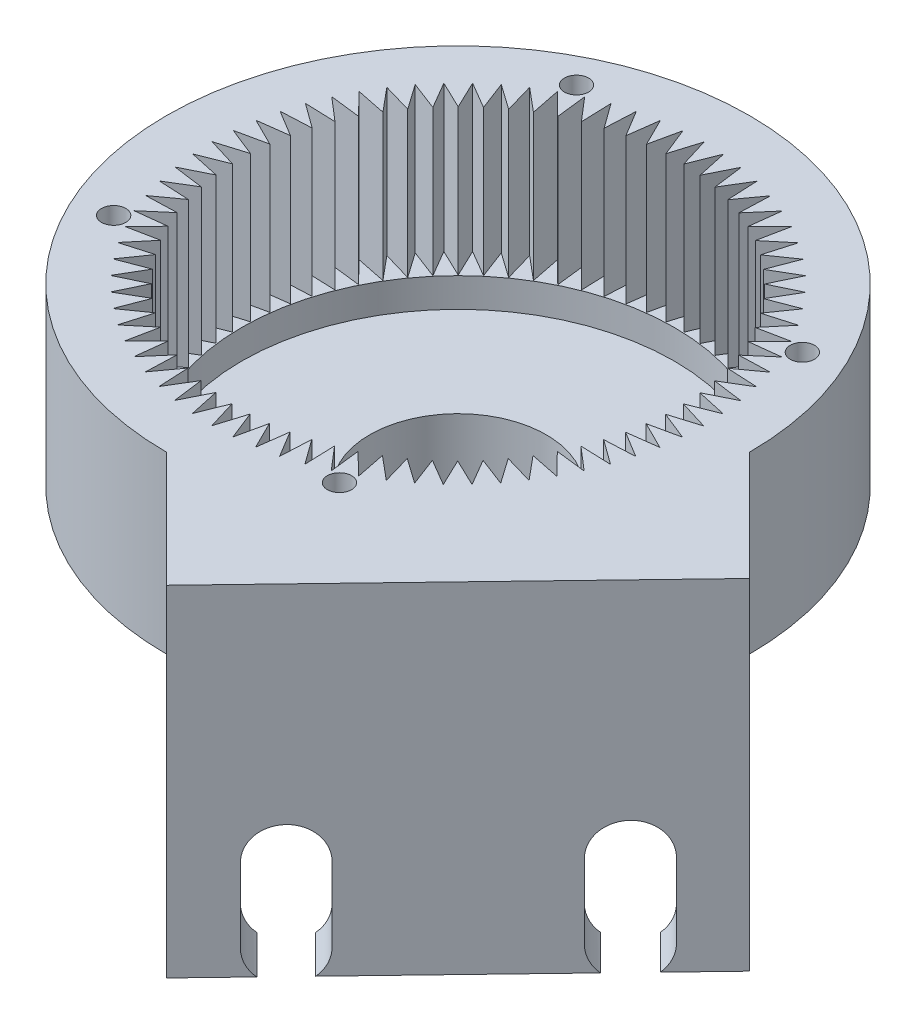
from build123d import *

# Parameters (mm, degrees)
SKETCH1_R                = 23
BOSS_EXTRUDE1_DEPTH      = 2
SKETCH2_R                = 30
SKETCH2_R_2              = 22.25
BOSS_EXTRUDE2_DEPTH      = 18
SKETCH3_R                = 9.1
CUT_EXTRUDE1_DEPTH       = 10
CUT_EXTRUDE8_DEPTH       = 15
SKETCH5_R                = 1.25
CUT_EXTRUDE3_DEPTH       = 47.904157598
SKETCH8_R                = 2.5
CUT_EXTRUDE5_DEPTH       = 2
BOSS_EXTRUDE3_DEPTH      = 20
BOSS_EXTRUDE4_DEPTH      = 17
CUT_EXTRUDE14_DEPTH      = 17
SKETCH19_R               = 10.9
SKETCH19_R_2             = 9.1
BOSS_EXTRUDE5_DEPTH      = 16
CUT_EXTRUDE15_DEPTH      = 62.480682567
CUT_EXTRUDE15_DEPTH_BACK = 62.480682567
SKETCH20_R               = 0.75


with BuildPart() as part:
    # Sketch1 → Boss-Extrude1 (new body)
    with BuildSketch(Plane(origin=(0, 0, 0), x_dir=(1, 0, 0), z_dir=(0, 1, 0))):
        Circle(SKETCH1_R)
    extrude(amount=-BOSS_EXTRUDE1_DEPTH)

    # Sketch2 → Boss-Extrude2 (add)
    with BuildSketch(Plane(origin=(0, 0, 0), x_dir=(1, 0, 0), z_dir=(0, 1, 0))):
        Circle(SKETCH2_R)
        Circle(SKETCH2_R_2, mode=Mode.SUBTRACT)
    extrude(amount=BOSS_EXTRUDE2_DEPTH)

    # Sketch3 → Cut-Extrude1 (cut)
    with BuildSketch(Plane(origin=(0, 0, 0), x_dir=(1, 0, 0), z_dir=(0, 1, 0))):
        Circle(SKETCH3_R)
    extrude(amount=-CUT_EXTRUDE1_DEPTH, mode=Mode.SUBTRACT)

    # Sketch10 → Cut-Extrude8 (cut)
    with BuildSketch(Plane(origin=(0, 18, 0), x_dir=(1, 0, 0), z_dir=(0, 1, 0))):
        Polygon((8.197658432, -23.951336041), (8.092989373, -20.798756228), (10.147343218, -23.192361327), (9.782693678, -20.059192674), (12.027693206, -22.274975203), (11.405554113, -19.18262043), (13.8258637, -21.205444346), (12.950484894, -18.175027372), (15.529571371, -19.991074737), (14.406932578, -17.043296382), (17.12717817, -18.640161752), (15.76494815, -15.795158331), (18.607770822, -17.161933495), (17.015254988, -14.439139267), (19.961235377, -15.566487766), (18.149312226, -12.984502175), (21.1783263, -13.864723075), (19.159373106, -11.441183702), (22.250729627, -12.068264202), (20.038537886, -9.819726278), (23.171119755, -10.189382782), (20.78080098, -8.131206101), (23.933209485, -8.24091348), (21.381091978, -6.387157476), (24.531792974, -6.236166317), (21.835310284, -4.599494023), (24.962781287, -4.18883575), (22.140353126, -2.780427297), (25.223230339, -2.112907122), (22.294136753, -0.942383368), (25.311360998, -0.02256113), (22.295610666, 0.902082061), (25.226571242, 2.067923043), (22.144764798, 2.740369419), (24.969440272, 4.144265269), (21.842629577, 4.559921342), (24.541724552, 6.192282027), (21.391268894, 6.348308443), (23.946345815, 8.197983286), (20.793766001, 8.093314226), (23.187371101, 10.147668071), (20.054202448, 9.783018531), (22.269984977, 12.028018059), (19.177630204, 11.405878966), (21.20045412, 13.826188553), (18.170037146, 12.950809747), (19.986084511, 15.529896225), (17.038306156, 14.407257431), (18.635171526, 17.127503023), (15.790168105, 15.765273003), (17.156943269, 18.608095675), (14.434149041, 17.015579841), (15.56149754, 19.96156023), (12.979511949, 18.14963708), (13.859732849, 21.178651154), (11.436193476, 19.159697959), (12.063273976, 22.25105448), (9.814736052, 20.038862739), (10.184392555, 23.171444608), (8.126215875, 20.781125833), (8.235923253, 23.933534338), (6.382167249, 21.381416831), (6.231176091, 24.532117827), (4.594503797, 21.835635137), (4.183845524, 24.96310614), (2.775437071, 22.14067798), (2.107916895, 25.223555192), (0.937393142, 22.294461606), (0.017570904, 25.311685851), (-0.907072287, 22.29593552), (-2.072913269, 25.226896096), (-2.745359646, 22.145089651), (-4.149255496, 24.969765125), (-4.564911568, 21.84295443), (-6.197272254, 24.542049405), (-6.353298669, 21.391593748), (-8.202973512, 23.946670668), (-8.098304452, 20.794090854), (-10.152658297, 23.187695954), (-9.788008758, 20.054527301), (-12.033008285, 22.27030983), (-11.410869192, 19.177955057), (-13.831178779, 21.200778973), (-12.955799973, 18.170361999), (-15.534886451, 19.986409364), (-14.412247657, 17.038631009), (-17.13249325, 18.635496379), (-15.77026323, 15.790492958), (-18.613085901, 17.157268122), (-17.020570067, 14.434473894), (-19.966550456, 15.561822393), (-18.154627306, 12.979836802), (-21.18364138, 13.860057702), (-19.164688185, 11.436518329), (-22.256044706, 12.063598829), (-20.043852966, 9.815060905), (-23.176434834, 10.184717409), (-20.786116059, 8.126540728), (-23.938524565, 8.236248107), (-21.386407057, 6.382492103), (-24.537108053, 6.231500944), (-21.840625363, 4.59482865), (-24.968096367, 4.184170377), (-22.145668206, 2.775761924), (-25.228545419, 2.108241749), (-22.299451833, 0.937717995), (-25.316676078, 0.017895757), (-22.300925746, -0.906747434), (-25.231886322, -2.072588416), (-22.150079877, -2.745034793), (-24.974755351, -4.148930642), (-21.847944656, -4.564586715), (-24.547039632, -6.1969474), (-21.396583974, -6.352973816), (-23.951660894, -8.202648659), (-20.799081081, -8.097979599), (-23.19268618, -10.152333444), (-20.059517528, -9.787683904), (-22.275300056, -12.032683432), (-19.182945283, -11.410544339), (-21.2057692, -13.830853926), (-18.175352225, -12.95547512), (-19.991399591, -15.534561598), (-17.043621235, -14.411922804), (-18.640486605, -17.132168397), (-15.795483184, -15.769938376), (-17.162258349, -18.612761048), (-14.43946412, -17.020245214), (-15.566812619, -19.966225603), (-12.984827029, -18.154302453), (-13.865047928, -21.183316527), (-11.441508556, -19.164363332), (-12.068589055, -22.255719853), (-9.820051131, -20.043528112), (-10.189707635, -23.176109981), (-8.131530954, -20.785791206), (-8.241238333, -23.938199712), (-6.387482329, -21.386082204), (-6.23649117, -24.5367832), (-4.599818876, -21.84030051), (-4.189160603, -24.967771514), (-2.78075215, -22.145343353), (-2.113231975, -25.228220565), (-0.942708221, -22.29912698), (-0.022885983, -25.316351224), (0.901757208, -22.300600893), (2.067598189, -25.231561469), (2.740044566, -22.149755024), (4.143940416, -24.974430498), (4.559596489, -21.847619803), (6.191957174, -24.546714778), (6.34798359, -21.396259121), align=None)
    extrude(amount=-CUT_EXTRUDE8_DEPTH, mode=Mode.SUBTRACT)

    # Sketch5 → Cut-Extrude3 (cut, through all)
    with BuildSketch(Plane(origin=(0, 18, 0), x_dir=(1, 0, 0), z_dir=(0, 1, 0))):
        with Locations((23.816653914, 11.619681422)):
            Circle(SKETCH5_R)
        with Locations((11.619681422, -23.816653914)):
            Circle(SKETCH5_R)
        with Locations((-23.816653914, -11.619681422)):
            Circle(SKETCH5_R)
        with Locations((-11.619681422, 23.816653914)):
            Circle(SKETCH5_R)
    extrude(amount=-CUT_EXTRUDE3_DEPTH, mode=Mode.SUBTRACT)

    # Sketch8 → Cut-Extrude5 (cut)
    with BuildSketch(Plane(origin=(0, 0, 0), x_dir=(-1, 0, 0), z_dir=(0, -1, 0))):
        with Locations((-23.816653914, 11.619681422)):
            Circle(SKETCH8_R)
        with Locations((11.619681422, 23.816653914)):
            Circle(SKETCH8_R)
        with Locations((23.816653914, -11.619681422)):
            Circle(SKETCH8_R)
        with Locations((-11.619681422, -23.816653914)):
            Circle(SKETCH8_R)
    extrude(amount=-CUT_EXTRUDE5_DEPTH, mode=Mode.SUBTRACT)



with BuildPart() as body_2:
    # Sketch12 → Boss-Extrude3 (new body)
    with BuildSketch(Plane.XZ.offset(-3)):
        Polygon((41.255489922, 11.255489922), (11.863625735, 41.863625735), (7.797761743, 37.797761743), (37.797761743, 7.797761743), align=None)
    extrude(amount=BOSS_EXTRUDE3_DEPTH)


with BuildPart() as part_1:
    add(part.part)

    add(body_2.part)  # Boss-Extrude4 merges body 2
    # Sketch11 → Boss-Extrude4 (add)
    with BuildSketch(Plane(origin=(0, 18, 0), x_dir=(1, 0, 0), z_dir=(0, 1, 0))):
        Polygon((0, -30), (11.863625735, -41.863625735), (41.255489922, -11.255489922), (30, 0), (26.221732839, -11.255489922), (13.334234143, -25.83269291), align=None)
    extrude(amount=-BOSS_EXTRUDE4_DEPTH)

    # Sketch14 → Cut-Extrude14 (cut)
    with BuildSketch(Plane(origin=(22.797761743, 0, 22.797761743), x_dir=(-0.7071067811865475, 0, 0.7071067811865477), z_dir=(-0.7071067811865477, 0, -0.7071067811865475))):
        with BuildLine():
            Line((-9.196858363, -6.783955956), (-9.196858363, -14.448078877))
            ThreePointArc((-9.196858363, -14.448078877), (-12.547911226, -17.79913174), (-15.898964089, -14.448078877))
            Line((-15.898964089, -14.448078877), (-15.898964089, -6.783955956))
            ThreePointArc((-15.898964089, -6.783955956), (-12.547911226, -3.432903093), (-9.196858363, -6.783955956))
        make_face()
        with BuildLine():
            Line((15.832390249, -6.783955956), (15.832390249, -14.448078877))
            ThreePointArc((15.832390249, -14.448078877), (12.497958792, -17.782510333), (9.163527336, -14.448078877))
            Line((9.163527336, -14.448078877), (9.163527336, -6.783955956))
            ThreePointArc((9.163527336, -6.783955956), (12.497958792, -3.4495245), (15.832390249, -6.783955956))
        make_face()
    extrude(amount=-CUT_EXTRUDE14_DEPTH, mode=Mode.SUBTRACT)

    # Sketch19 → Boss-Extrude5 (add)
    with BuildSketch(Plane.XZ.offset(2)):
        Circle(SKETCH19_R)
        Circle(SKETCH19_R_2, mode=Mode.SUBTRACT)
    extrude(amount=BOSS_EXTRUDE5_DEPTH)

    # Sketch20 → Cut-Extrude15 (cut, two sides: drawn at the far end of the back side and taken through both)
    with BuildSketch(Plane(origin=(0.556349186, 0, -0.556349186), x_dir=(0.7071067811865562, 0, 0.7071067811865388), z_dir=(-0.7071067811865388, 0, 0.7071067811865562)).offset(-CUT_EXTRUDE15_DEPTH_BACK)):
        with Locations((0, -8.994497393)):
            Circle(SKETCH20_R)
        with Locations((0, -13.000969862)):
            Circle(SKETCH20_R)
    extrude(amount=CUT_EXTRUDE15_DEPTH + CUT_EXTRUDE15_DEPTH_BACK, mode=Mode.SUBTRACT)


solid = part_1.part
